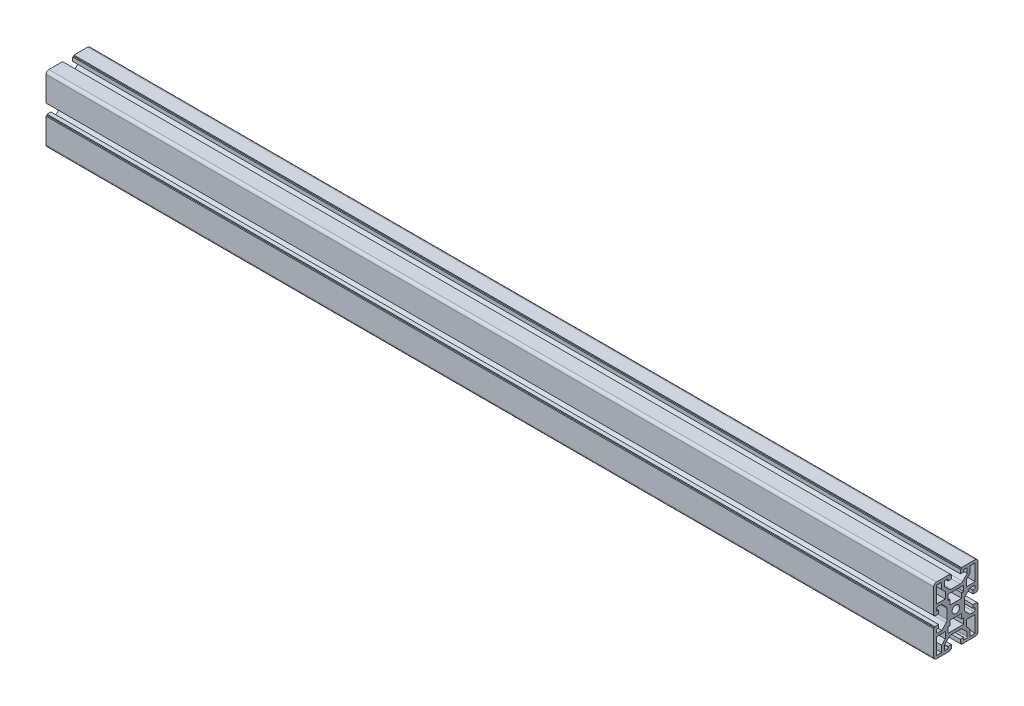
from build123d import *

# Parameters (mm, degrees)
SKETCH_19_R           = 3.4
MEMBER_4060_A_1_DEPTH = 800
SKETCH_14_R           = 3
CUT_EXTRUDE_1_DEPTH   = 10


with BuildPart() as part:
    # 草图19 → Member 4060-a _1 (new body)
    with BuildSketch(Plane.YZ):
        with BuildLine():
            Line((10.25, 16.5), (10.25, 12.765240679))
            Line((10.25, 12.765240679), (6.149583391, 8.63609737))
            ThreePointArc((6.149583391, 8.63609737), (5.17375715, 7.980369349), (4.020871182, 7.75))
            Line((4.020871182, 7.75), (-4.020871182, 7.75))
            ThreePointArc((-4.020871182, 7.75), (-5.17375715, 7.980369349), (-6.149583391, 8.63609737))
            Line((-6.149583391, 8.63609737), (-10.25, 12.765240679))
            Line((-10.25, 12.765240679), (-10.25, 16.5))
            ThreePointArc((-10.25, 16.5), (-9.957106781, 17.207106781), (-9.25, 17.5))
            Line((-9.25, 17.5), (-8, 17.5))
            ThreePointArc((-8, 17.5), (-7.292893219, 17.207106781), (-7, 16.5))
            Line((-7, 16.5), (-7, 15.5))
            Line((-7, 15.5), (-4.1, 15.5))
            Line((-4.1, 15.5), (-4.1, 19))
            Line((-4.1, 19), (-5.1, 19))
            Line((-5.1, 19), (-5.1, 20))
            Line((-5.1, 20), (-27.5, 20))
            ThreePointArc((-27.5, 20), (-29.267766953, 19.267766953), (-30, 17.5))
            Line((-30, 17.5), (-30, 5.1))
            Line((-30, 5.1), (-29, 5.1))
            Line((-29, 5.1), (-29, 4.1))
            Line((-29, 4.1), (-25.5, 4.1))
            Line((-25.5, 4.1), (-25.5, 7))
            Line((-25.5, 7), (-26.5, 7))
            ThreePointArc((-26.5, 7), (-27.207106781, 7.292893219), (-27.5, 8))
            Line((-27.5, 8), (-27.5, 9.25))
            ThreePointArc((-27.5, 9.25), (-27.207106781, 9.957106781), (-26.5, 10.25))
            Line((-26.5, 10.25), (-22.765240679, 10.25))
            Line((-22.765240679, 10.25), (-18.63609737, 6.149583391))
            ThreePointArc((-18.63609737, 6.149583391), (-17.980369349, 5.17375715), (-17.75, 4.020871182))
            Line((-17.75, 4.020871182), (-17.75, -4.020871182))
            ThreePointArc((-17.75, -4.020871182), (-17.980369349, -5.17375715), (-18.63609737, -6.149583391))
            Line((-18.63609737, -6.149583391), (-22.765240679, -10.25))
            Line((-22.765240679, -10.25), (-26.5, -10.25))
            ThreePointArc((-26.5, -10.25), (-27.207106781, -9.957106781), (-27.5, -9.25))
            Line((-27.5, -9.25), (-27.5, -8))
            ThreePointArc((-27.5, -8), (-27.207106781, -7.292893219), (-26.5, -7))
            Line((-26.5, -7), (-25.5, -7))
            Line((-25.5, -7), (-25.5, -4.1))
            Line((-25.5, -4.1), (-29, -4.1))
            Line((-29, -4.1), (-29, -5.1))
            Line((-29, -5.1), (-30, -5.1))
            Line((-30, -5.1), (-30, -17.5))
            ThreePointArc((-30, -17.5), (-29.267766953, -19.267766953), (-27.5, -20))
            Line((-27.5, -20), (-5.1, -20))
            Line((-5.1, -20), (-5.1, -19))
            Line((-5.1, -19), (-4.1, -19))
            Line((-4.1, -19), (-4.1, -15.5))
            Line((-4.1, -15.5), (-7, -15.5))
            Line((-7, -15.5), (-7, -16.5))
            ThreePointArc((-7, -16.5), (-7.292893219, -17.207106781), (-8, -17.5))
            Line((-8, -17.5), (-9.25, -17.5))
            ThreePointArc((-9.25, -17.5), (-9.957106781, -17.207106781), (-10.25, -16.5))
            Line((-10.25, -16.5), (-10.25, -12.765240679))
            Line((-10.25, -12.765240679), (-6.149583391, -8.63609737))
            ThreePointArc((-6.149583391, -8.63609737), (-5.17375715, -7.980369349), (-4.020871182, -7.75))
            Line((-4.020871182, -7.75), (4.020871182, -7.75))
            ThreePointArc((4.020871182, -7.75), (5.17375715, -7.980369349), (6.149583391, -8.63609737))
            Line((6.149583391, -8.63609737), (10.25, -12.765240679))
            Line((10.25, -12.765240679), (10.25, -16.5))
            ThreePointArc((10.25, -16.5), (9.957106781, -17.207106781), (9.25, -17.5))
            Line((9.25, -17.5), (8, -17.5))
            ThreePointArc((8, -17.5), (7.292893219, -17.207106781), (7, -16.5))
            Line((7, -16.5), (7, -15.5))
            Line((7, -15.5), (4.1, -15.5))
            Line((4.1, -15.5), (4.1, -19))
            Line((4.1, -19), (5.1, -19))
            Line((5.1, -19), (5.1, -20))
            Line((5.1, -20), (27.5, -20))
            ThreePointArc((27.5, -20), (29.267766953, -19.267766953), (30, -17.5))
            Line((30, -17.5), (30, -5.1))
            Line((30, -5.1), (29, -5.1))
            Line((29, -5.1), (29, -4.1))
            Line((29, -4.1), (25.5, -4.1))
            Line((25.5, -4.1), (25.5, -7))
            Line((25.5, -7), (26.5, -7))
            ThreePointArc((26.5, -7), (27.207106781, -7.292893219), (27.5, -8))
            Line((27.5, -8), (27.5, -9.25))
            ThreePointArc((27.5, -9.25), (27.207106781, -9.957106781), (26.5, -10.25))
            Line((26.5, -10.25), (22.765240679, -10.25))
            Line((22.765240679, -10.25), (18.63609737, -6.149583391))
            ThreePointArc((18.63609737, -6.149583391), (17.980369349, -5.17375715), (17.75, -4.020871182))
            Line((17.75, -4.020871182), (17.75, 4.020871182))
            ThreePointArc((17.75, 4.020871182), (17.980369349, 5.17375715), (18.63609737, 6.149583391))
            Line((18.63609737, 6.149583391), (22.765240679, 10.25))
            Line((22.765240679, 10.25), (26.5, 10.25))
            ThreePointArc((26.5, 10.25), (27.207106781, 9.957106781), (27.5, 9.25))
            Line((27.5, 9.25), (27.5, 8))
            ThreePointArc((27.5, 8), (27.207106781, 7.292893219), (26.5, 7))
            Line((26.5, 7), (25.5, 7))
            Line((25.5, 7), (25.5, 4.1))
            Line((25.5, 4.1), (29, 4.1))
            Line((29, 4.1), (29, 5.1))
            Line((29, 5.1), (30, 5.1))
            Line((30, 5.1), (30, 17.5))
            ThreePointArc((30, 17.5), (29.267766953, 19.267766953), (27.5, 20))
            Line((27.5, 20), (5.1, 20))
            Line((5.1, 20), (5.1, 19))
            Line((5.1, 19), (4.1, 19))
            Line((4.1, 19), (4.1, 15.5))
            Line((4.1, 15.5), (7, 15.5))
            Line((7, 15.5), (7, 16.5))
            ThreePointArc((7, 16.5), (7.292893219, 17.207106781), (8, 17.5))
            Line((8, 17.5), (9.25, 17.5))
            ThreePointArc((9.25, 17.5), (9.957106781, 17.207106781), (10.25, 16.5))
        make_face()
        Circle(SKETCH_19_R, mode=Mode.SUBTRACT)
        Polygon((27.5, -12.75), (27.5, -17.5), (12.75, -17.5), (12.75, -9.5), (18.462046185, -9.5), (21.734815036, -12.75), align=None, mode=Mode.SUBTRACT)
        Polygon((5.9, 5.25), (10.25, 5.25), (10.25, 7), (15.25, 7), (15.25, -7), (10.25, -7), (10.25, -5.25), (5.9, -5.25), align=None, mode=Mode.SUBTRACT)
        Polygon((-27.5, 12.75), (-27.5, 17.5), (-12.75, 17.5), (-12.75, 9.5), (-18.462046185, 9.5), (-21.734815036, 12.75), align=None, mode=Mode.SUBTRACT)
        Polygon((27.5, 17.5), (27.5, 12.75), (21.734815036, 12.75), (18.462046185, 9.5), (12.75, 9.5), (12.75, 17.5), align=None, mode=Mode.SUBTRACT)
        Polygon((-10.25, 7), (-10.25, 5.25), (-5.9, 5.25), (-5.9, -5.25), (-10.25, -5.25), (-10.25, -7), (-15.25, -7), (-15.25, 7), align=None, mode=Mode.SUBTRACT)
        Polygon((-27.5, -17.5), (-27.5, -12.75), (-21.734815036, -12.75), (-18.462046185, -9.5), (-12.75, -9.5), (-12.75, -17.5), align=None, mode=Mode.SUBTRACT)
    extrude(amount=MEMBER_4060_A_1_DEPTH)

    # 草图14 → 切除-拉伸1 (cut)
    with BuildSketch(Plane(origin=(0, -12.75, 0), x_dir=(-1, 0, 0), z_dir=(0, -1, 0))):
        with Locations(Location((-785, 0, 0), (0, 0, 90))):
            Circle(SKETCH_14_R)
    extrude(amount=-CUT_EXTRUDE_1_DEPTH, mode=Mode.SUBTRACT)


solid = part.part
